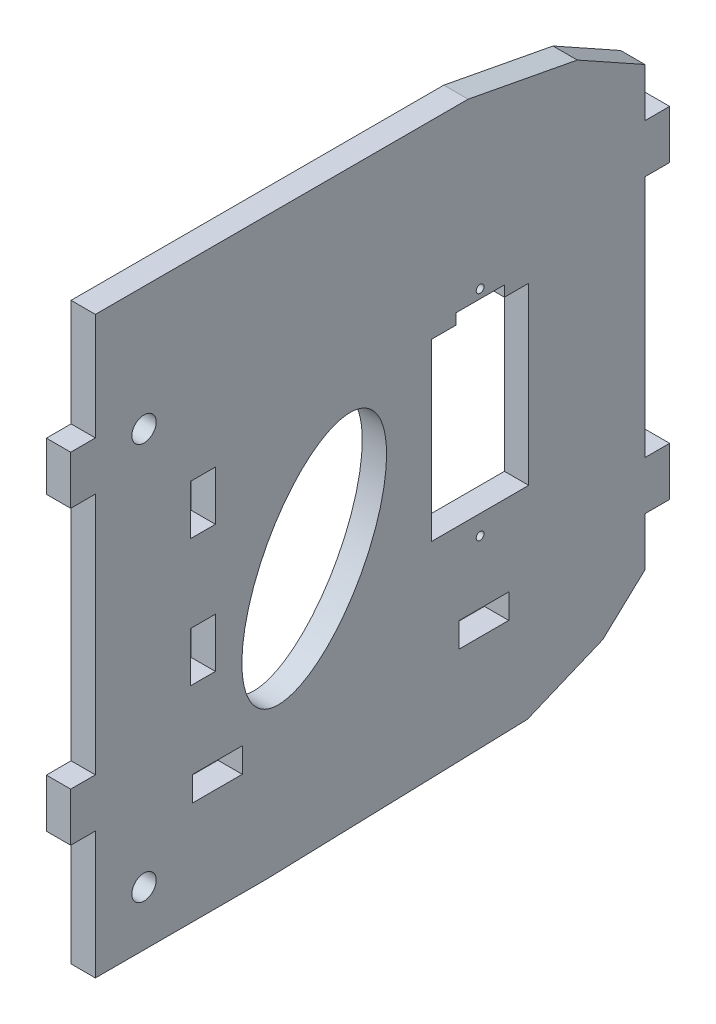
from build123d import *

# Parameters (mm, degrees)
SKETCH1_W                            = 71.755
SKETCH1_H                            = 57.15
MAIN_BODY_DEPTH                      = 3.175
SKETCH2_W                            = 3.2258
SKETCH2_H                            = 6.35
TABS_FRONT_DEPTH                     = 3.175
SKETCH3_R                            = 0.508
CUT_FOR_EAR_MOTOR_DEPTH              = 4.175
SKETCH4_W                            = 3.2258
SKETCH4_H                            = 6.477
SKETCH4_W_2                          = 6.477
SKETCH4_H_2                          = 3.2258
CUT_FOR_TABS_DEPTH                   = 4.175
BOSS_EXTRUDE1_DEPTH                  = 3.175
SKETCH6_R                            = 1.5875
CUT_FOR_FACE_PLATE_MOUNT_SCREW_DEPTH = 4.175
SKETCH7_RX                           = 15.24
SKETCH7_RY                           = 7.62
ELLIPSE_CUT_DEPTH                    = 4.175


with BuildPart() as part:
    # Sketch1 → main body (new body)
    with BuildSketch(Plane(origin=(0, 0, 0), x_dir=(0, 0, -1), z_dir=(1, 0, 0))):
        Rectangle(SKETCH1_W, SKETCH1_H)
    extrude(amount=MAIN_BODY_DEPTH)

    # Sketch2 → tabs front (add)
    with BuildSketch(Plane.ZY):
        with Locations((37.4904, 19.05)):
            Rectangle(SKETCH2_W, SKETCH2_H)
        with Locations((37.4904, -19.05)):
            Rectangle(SKETCH2_W, SKETCH2_H)
    tabs_front = extrude(amount=-TABS_FRONT_DEPTH)

    # mirror of tabs (back): tabs front across plane
    add(tabs_front.mirror(Plane.XY))

    # Sketch3 → cut for ear motor (cut, through all)
    with BuildSketch(Plane.ZY):
        with Locations((-14.356162211, 13.97)):
            Circle(SKETCH3_R)
        with Locations((-14.356162211, -13.97)):
            Circle(SKETCH3_R)
        Polygon((-20.706162211, -11.43), (-8.006162211, -11.43), (-8.006162211, 11.43), (-11.181162211, 11.43), (-11.181162211, 12.827), (-17.531162211, 12.827), (-17.531162211, 11.43), (-20.706162211, 11.43), align=None)
    extrude(amount=-CUT_FOR_EAR_MOTOR_DEPTH, mode=Mode.SUBTRACT)

    # Sketch4 → cut for tabs (cut, through all)
    with BuildSketch(Plane.ZY):
        with Locations((21.8186, 7.8613)):
            Rectangle(SKETCH4_W, SKETCH4_H)
        with Locations((21.8186, -8.7757)):
            Rectangle(SKETCH4_W, SKETCH4_H)
        with Locations((19.939, -23.7871)):
            Rectangle(SKETCH4_W_2, SKETCH4_H_2)
        with Locations((-14.859, -23.7871)):
            Rectangle(SKETCH4_W_2, SKETCH4_H_2)
    extrude(amount=-CUT_FOR_TABS_DEPTH, mode=Mode.SUBTRACT)

    # Sketch5 → Boss-Extrude1 (add)
    with BuildSketch(Plane.ZY):
        Polygon((-35.8775, -28.575), (35.8775, -28.575), (35.8775, -38.846719594), (13.523283037, -38.846719594), (-20.528592985, -37.801776478), (-30.363311769, -33.710859797), align=None)
        Polygon((-12.787335482, 36.195), (-27.046355521, 33.492436966), (-35.8775, 28.575), (35.8775, 28.575), (35.8775, 36.195), (26.200162008, 36.195), align=None)
    extrude(amount=-BOSS_EXTRUDE1_DEPTH)

    # Sketch6 → cut for face plate mount screw (cut, through all)
    with BuildSketch(Plane.ZY):
        with Locations((29.5275, 20.066)):
            Circle(SKETCH6_R)
        with Locations((29.5275, -31.734719594)):
            Circle(SKETCH6_R)
    extrude(amount=-CUT_FOR_FACE_PLATE_MOUNT_SCREW_DEPTH, mode=Mode.SUBTRACT)

    # Sketch7 → ellipse cut (cut, through all)
    with BuildSketch(Plane.ZY):
        with Locations(Location((7.3025, -5.715), (0, 0, -65))):
            Ellipse(SKETCH7_RX, SKETCH7_RY)
    extrude(amount=-ELLIPSE_CUT_DEPTH, mode=Mode.SUBTRACT)


solid = part.part
